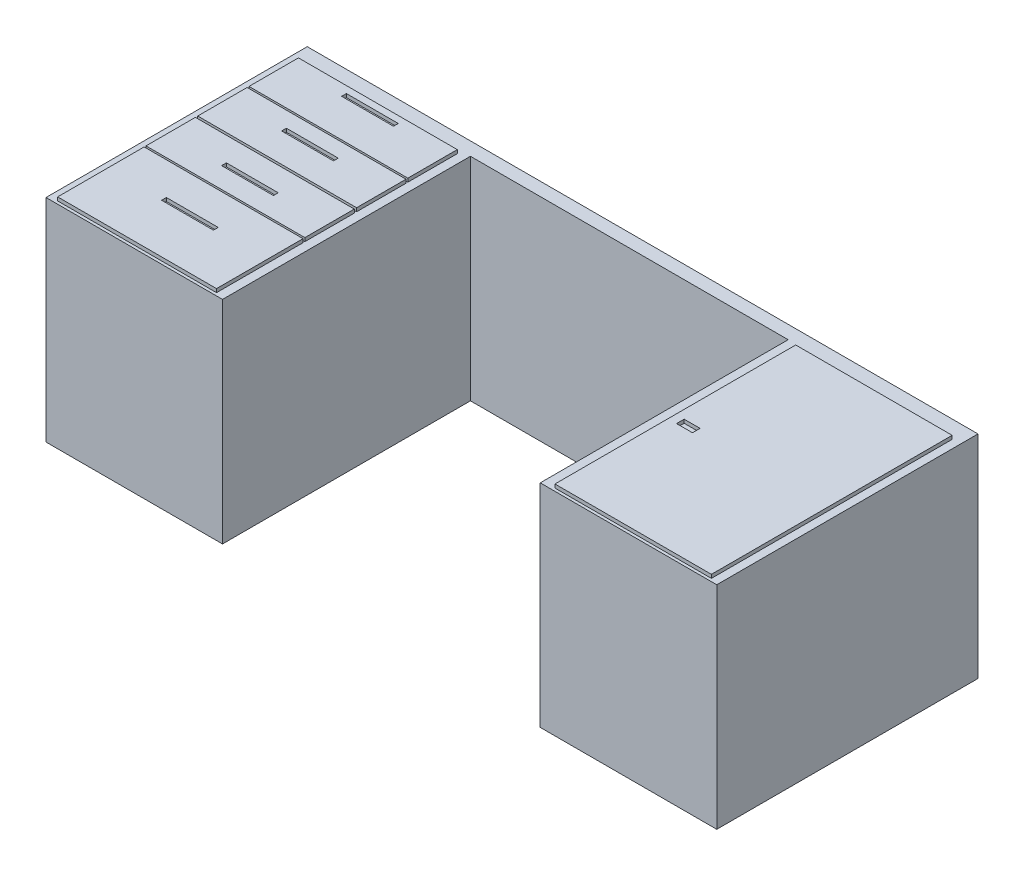
from build123d import *

# Parameters (mm, degrees)
BOSS_EXTRUDE1_DEPTH = 600
SKETCH2_W           = 450
SKETCH2_H           = 140
SKETCH2_W_2         = 146.91343935
SKETCH2_H_2         = 13.581682478
SKETCH2_H_3         = 245
SKETCH2_W_3         = 443.204970856
SKETCH2_H_4         = 681.963540889
SKETCH2_W_4         = 44.98901636
SKETCH2_H_5         = 21.550878859
BOSS_EXTRUDE2_DEPTH = 10


with BuildPart() as part:
    # Sketch1 → Boss-Extrude1 (new body)
    with BuildSketch(Plane(origin=(0, 0, 0), x_dir=(1, 0, 0), z_dir=(0, 1, 0))):
        Polygon((0, 0), (0, 740), (1900, 740), (1900, 0), (1400, 0), (1400, 702.263165655), (500, 702.263165655), (500, 0), align=None)
    extrude(amount=BOSS_EXTRUDE1_DEPTH)

    # Sketch2 → Boss-Extrude2 (add)
    with BuildSketch(Plane(origin=(0, 600, 0), x_dir=(1, 0, 0), z_dir=(0, 1, 0))):
        with Locations((250.001274905, 620)):
            Rectangle(SKETCH2_W, SKETCH2_H)
        with Locations((253.905576666, 663.689083521)):
            Rectangle(SKETCH2_W_2, SKETCH2_H_2, mode=Mode.SUBTRACT)
        with Locations((250.001274905, 474.789512045)):
            Rectangle(SKETCH2_W, SKETCH2_H)
        with Locations((253.905576666, 493.689083521)):
            Rectangle(SKETCH2_W_2, SKETCH2_H_2, mode=Mode.SUBTRACT)
        with Locations((250.001274905, 328.246947066)):
            Rectangle(SKETCH2_W, SKETCH2_H)
        with Locations((253.905576666, 323.689083521)):
            Rectangle(SKETCH2_W_2, SKETCH2_H_2, mode=Mode.SUBTRACT)
        with Locations((250.001274905, 130.536459111)):
            Rectangle(SKETCH2_W, SKETCH2_H_3)
        with Locations((253.905576666, 153.689083521)):
            Rectangle(SKETCH2_W_2, SKETCH2_H_2, mode=Mode.SUBTRACT)
        with Locations((1655.213820174, 349.018229555)):
            Rectangle(SKETCH2_W_3, SKETCH2_H_4)
        with Locations((1480.203434269, 339.22456057)):
            Rectangle(SKETCH2_W_4, SKETCH2_H_5, mode=Mode.SUBTRACT)
    extrude(amount=BOSS_EXTRUDE2_DEPTH)


solid = part.part
